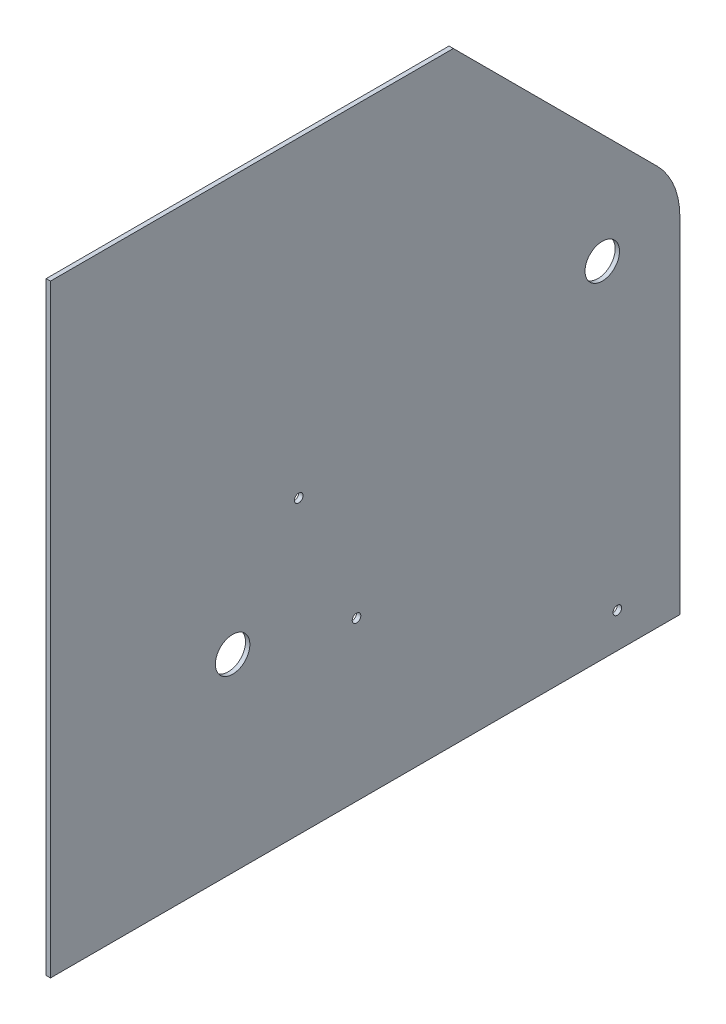
from build123d import *

# Parameters (mm, degrees)
SKETCH1_R           = 12.7
BOSS_EXTRUDE1_DEPTH = 3.175
CUT_EXTRUDE1_REACH  = 5.175
SKETCH2_R           = 3.175
BOSS_EXTRUDE2_DEPTH = 3.175
BOSS_EXTRUDE3_DEPTH = 3.175
CUT_EXTRUDE2_REACH  = 5.175
SKETCH5_R           = 12.7
BOSS_EXTRUDE4_DEPTH = 3.175
SKETCH7_W           = 739.335123301
SKETCH7_H           = 711.050730063
CUT_EXTRUDE3_DEPTH  = 3.175


with BuildPart() as part:
    # Sketch1 → Boss-Extrude1 (new body)
    with BuildSketch(Plane(origin=(0, 0, 0), x_dir=(0, 0, -1), z_dir=(1, 0, 0))):
        with BuildLine():
            Line((-217.899389282, 130.521477737), (17.58316119, 54.3778902))
            ThreePointArc((17.58316119, 54.3778902), (46.211471314, 33.624729277), (57.15, 0))
            Line((57.15, 0), (57.15, -254))
            Line((57.15, -254), (0, -254))
            ThreePointArc((0, -254), (-220.984677461, -125.226883405), (-217.899389282, 130.521477737))
        make_face()
        Circle(SKETCH1_R, mode=Mode.SUBTRACT)
    extrude(amount=BOSS_EXTRUDE1_DEPTH)

    # Sketch2 → Cut-Extrude1 (cut, up to next)
    with BuildSketch(Plane(origin=(3.175, 0, 0), x_dir=(0, 0, -1), z_dir=(1, 0, 0)), mode=Mode.PRIVATE) as cut_extrude1_sk1:
        with Locations((11.103289152, -228.181271676)):
            Circle(SKETCH2_R)
    cut_extrude1_tool1 = extrude(cut_extrude1_sk1.sketch, amount=-CUT_EXTRUDE1_REACH, mode=Mode.PRIVATE) & part.part
    add(cut_extrude1_tool1.solids().sort_by_distance((3.175, -228.181272, -11.103289))[0], mode=Mode.SUBTRACT)
    # Sketch2 → Cut-Extrude1 (cut, up to next)
    with BuildSketch(Plane(origin=(3.175, 0, 0), x_dir=(0, 0, -1), z_dir=(1, 0, 0)), mode=Mode.PRIVATE) as cut_extrude1_sk2:
        with Locations((-180.989788445, -137.156185968)):
            Circle(SKETCH2_R)
    cut_extrude1_tool2 = extrude(cut_extrude1_sk2.sketch, amount=-CUT_EXTRUDE1_REACH, mode=Mode.PRIVATE) & part.part
    add(cut_extrude1_tool2.solids().sort_by_distance((3.175, -137.156186, 180.989788))[0], mode=Mode.SUBTRACT)
    # Sketch2 → Cut-Extrude1 (cut, up to next)
    with BuildSketch(Plane(origin=(3.175, 0, 0), x_dir=(0, 0, -1), z_dir=(1, 0, 0)), mode=Mode.PRIVATE) as cut_extrude1_sk3:
        with Locations((-223.548763187, -39.27724509)):
            Circle(SKETCH2_R)
    cut_extrude1_tool3 = extrude(cut_extrude1_sk3.sketch, amount=-CUT_EXTRUDE1_REACH, mode=Mode.PRIVATE) & part.part
    add(cut_extrude1_tool3.solids().sort_by_distance((3.175, -39.277245, 223.548763))[0], mode=Mode.SUBTRACT)

    # Sketch3 → Boss-Extrude2 (add)
    with BuildSketch(Plane(origin=(3.175, 0, 0), x_dir=(0, 0, -1), z_dir=(1, 0, 0))):
        with BuildLine():
            Line((0, -254), (-254, -254))
            Line((-254, -254), (-254, 0))
            ThreePointArc((-254, 0), (-179.605122421, -179.605122421), (0, -254))
        make_face()
    extrude(amount=-BOSS_EXTRUDE2_DEPTH)

    # Sketch4 → Boss-Extrude3 (add)
    with BuildSketch(Plane(origin=(3.175, 0, 0), x_dir=(0, 0, -1), z_dir=(1, 0, 0))):
        with BuildLine():
            Line((-254, -254), (-406.4, -254))
            Line((-406.4, -254), (-406.4, 191.473394235))
            Line((-406.4, 191.473394235), (-217.899389282, 130.521477737))
            ThreePointArc((-217.899389282, 130.521477737), (-244.808542414, 67.710985528), (-254, 0))
            Line((-254, 0), (-254, -254))
        make_face()
    extrude(amount=-BOSS_EXTRUDE3_DEPTH)

    # Sketch5 → Cut-Extrude2 (cut, up to next)
    with BuildSketch(Plane(origin=(3.175, 0, 0), x_dir=(0, 0, -1), z_dir=(1, 0, 0)), mode=Mode.PRIVATE) as cut_extrude2_sk1:
        with Locations((-272.235522473, -114.629596607)):
            Circle(SKETCH5_R)
    cut_extrude2_tool1 = extrude(cut_extrude2_sk1.sketch, amount=-CUT_EXTRUDE2_REACH, mode=Mode.PRIVATE) & part.part
    add(cut_extrude2_tool1.solids().sort_by_distance((3.175, -114.629597, 272.235522))[0], mode=Mode.SUBTRACT)

    # Sketch6 → Boss-Extrude4 (add)
    with BuildSketch(Plane(origin=(3.175, 0, 0), x_dir=(0, 0, -1), z_dir=(1, 0, 0))):
        with BuildLine():
            Line((40.411152545, 40.411152545), (-406.4, 487.22230509))
            Line((-406.4, 487.22230509), (-406.4, 191.473394235))
            Line((-406.4, 191.473394235), (17.58316119, 54.3778902))
            ThreePointArc((17.58316119, 54.3778902), (29.826205702, 48.749563623), (40.411152545, 40.411152545))
        make_face()
    extrude(amount=-BOSS_EXTRUDE4_DEPTH)

    # Sketch7 → Cut-Extrude3 (cut)
    with BuildSketch(Plane(origin=(3.175, 0, 0), x_dir=(0, 0, -1), z_dir=(1, 0, 0))):
        with Locations((-36.73243835, 546.025365032)):
            Rectangle(SKETCH7_W, SKETCH7_H)
    extrude(amount=-CUT_EXTRUDE3_DEPTH, mode=Mode.SUBTRACT)


solid = part.part
